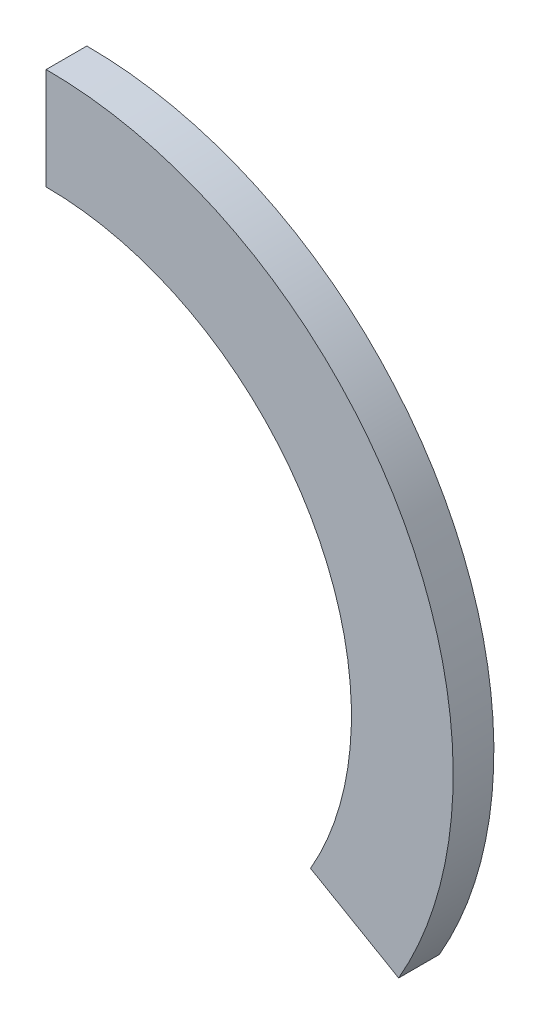
from build123d import *

# Parameters (mm, degrees)
BOSS_EXTRUDE2_DEPTH = 8


with BuildPart() as part:
    # Sketch2 → Boss-Extrude2 (new body)
    with BuildSketch(Plane.XY):
        with BuildLine():
            Line((0, 60), (0, 80))
            ThreePointArc((0, 80), (69.282032509, 39.999999643), (69.282031891, -40.000000714))
            Line((69.282031891, -40.000000714), (51.961523815, -30.000000714))
            ThreePointArc((51.961523815, -30.000000714), (51.961524433, 29.999999643), (0, 60))
        make_face()
    extrude(amount=BOSS_EXTRUDE2_DEPTH)


solid = part.part
